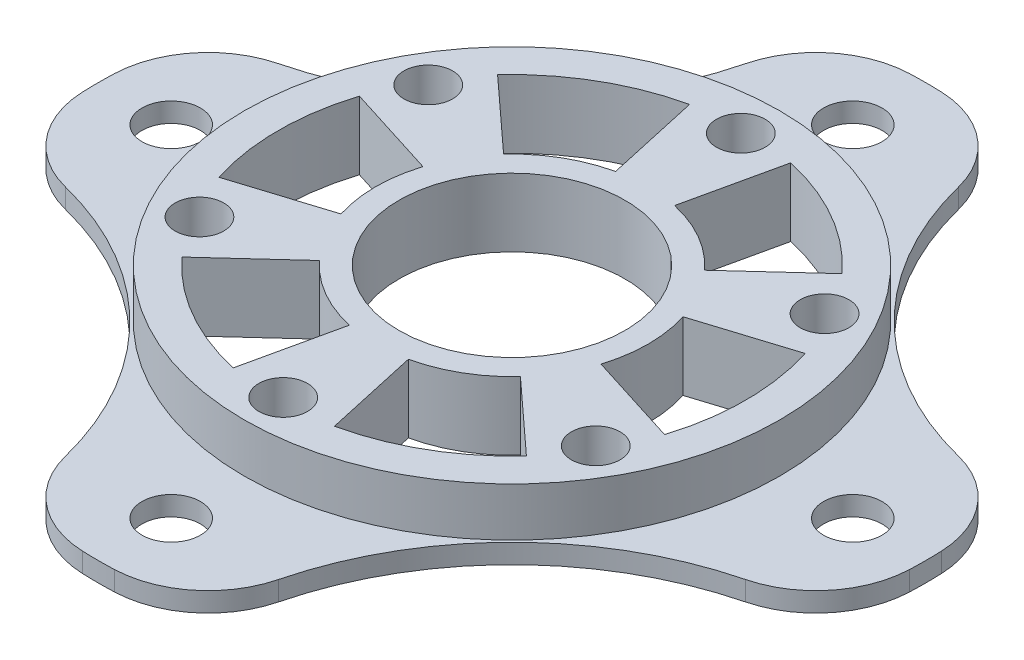
from build123d import *

# Parameters (mm, degrees)
SKETCH1_R           = 27.5
BOSS_EXTRUDE1_DEPTH = 5
SKETCH2_R           = 42.5
BOSS_EXTRUDE2_DEPTH = 2
SKETCH3_R           = 3
CUT_EXTRUDE1_DEPTH  = 2
SKETCH4_R           = 11.6
SKETCH4_R_2         = 2.5
CUT_EXTRUDE2_DEPTH  = 8
CUT_EXTRUDE3_DEPTH  = 8
FILLET1_R           = 10


with BuildPart() as part:
    # Sketch1 → Boss-Extrude1 (new body)
    with BuildSketch(Plane(origin=(0, 0, 0), x_dir=(1, 0, 0), z_dir=(0, 1, 0))):
        Circle(SKETCH1_R)
    extrude(amount=-BOSS_EXTRUDE1_DEPTH)

    # Sketch2 → Boss-Extrude2 (add)
    with BuildSketch(Plane.XZ.offset(5)):
        Circle(SKETCH2_R)
    extrude(amount=BOSS_EXTRUDE2_DEPTH)

    # Sketch3 → Cut-Extrude1 (cut)
    with BuildSketch(Plane(origin=(0, -5, 0), x_dir=(1, 0, 0), z_dir=(0, 1, 0))):
        with BuildLine():
            ThreePointArc((-41.306779105, 10), (-19.624107624, 19.624107624), (-10, 41.306779105))
            ThreePointArc((-10, 41.306779105), (-30.0520382, 30.0520382), (-41.306779105, 10))
        make_face()
        with Locations((0, 35)):
            Circle(SKETCH3_R)
        with BuildLine():
            ThreePointArc((41.306779105, 10), (30.0520382, 30.0520382), (10, 41.306779105))
            ThreePointArc((10, 41.306779105), (19.624107624, 19.624107624), (41.306779105, 10))
        make_face()
        with Locations((35, 0)):
            Circle(SKETCH3_R)
        with Locations((0, -35)):
            Circle(SKETCH3_R)
        with BuildLine():
            ThreePointArc((41.306779105, -10), (19.624107624, -19.624107624), (10, -41.306779105))
            ThreePointArc((10, -41.306779105), (30.0520382, -30.0520382), (41.306779105, -10))
        make_face()
        with BuildLine():
            ThreePointArc((-10, -41.306779105), (-19.624107624, -19.624107624), (-41.306779105, -10))
            ThreePointArc((-41.306779105, -10), (-30.0520382, -30.0520382), (-10, -41.306779105))
        make_face()
        with Locations((-35, 0)):
            Circle(SKETCH3_R)
    extrude(amount=-CUT_EXTRUDE1_DEPTH, mode=Mode.SUBTRACT)

    # Sketch4 → Cut-Extrude2 (cut, through all)
    with BuildSketch(Plane(origin=(0, 0, 0), x_dir=(1, 0, 0), z_dir=(0, 1, 0))):
        Circle(SKETCH4_R)
        with Locations((0, 23.5)):
            Circle(SKETCH4_R_2)
        with Locations((20.351596989, 11.75)):
            Circle(SKETCH4_R_2)
        with Locations((20.351596989, -11.75)):
            Circle(SKETCH4_R_2)
        with Locations((0, -23.5)):
            Circle(SKETCH4_R_2)
        with Locations((-20.351596989, -11.75)):
            Circle(SKETCH4_R_2)
        with Locations((-20.351596989, 11.75)):
            Circle(SKETCH4_R_2)
    extrude(amount=-CUT_EXTRUDE2_DEPTH, mode=Mode.SUBTRACT)

    # Sketch5 → Cut-Extrude3 (cut, through all)
    with BuildSketch(Plane(origin=(0, 0, 0), x_dir=(1, 0, 0), z_dir=(0, 1, 0))):
        with BuildLine():
            Line((-17.694656083, 16.214164983), (-10.321882715, 9.458262907))
            ThreePointArc((-10.321882715, 9.458262907), (-7, 12.124355653), (-3.030154595, 13.6681441))
            Line((-3.030154595, 13.6681441), (-5.194550735, 23.431104171))
            ThreePointArc((-5.194550735, 23.431104171), (-12, 20.784609691), (-17.694656083, 16.214164983))
        make_face()
        with BuildLine():
            Line((17.694656083, 16.214164983), (10.321882715, 9.458262907))
            ThreePointArc((10.321882715, 9.458262907), (7, 12.124355653), (3.030154595, 13.6681441))
            Line((3.030154595, 13.6681441), (5.194550735, 23.431104171))
            ThreePointArc((5.194550735, 23.431104171), (12, 20.784609691), (17.694656083, 16.214164983))
        make_face()
        with BuildLine():
            Line((22.889206818, -7.216939188), (13.35203731, -4.209881193))
            ThreePointArc((13.35203731, -4.209881193), (14, 0), (13.35203731, 4.209881193))
            Line((13.35203731, 4.209881193), (22.889206818, 7.216939188))
            ThreePointArc((22.889206818, 7.216939188), (24, 0), (22.889206818, -7.216939188))
        make_face()
        with BuildLine():
            Line((5.194550735, -23.431104171), (3.030154595, -13.6681441))
            ThreePointArc((3.030154595, -13.6681441), (7, -12.124355653), (10.321882715, -9.458262907))
            Line((10.321882715, -9.458262907), (17.694656083, -16.214164983))
            ThreePointArc((17.694656083, -16.214164983), (12, -20.784609691), (5.194550735, -23.431104171))
        make_face()
        with BuildLine():
            Line((-17.694656083, -16.214164983), (-10.321882715, -9.458262907))
            ThreePointArc((-10.321882715, -9.458262907), (-7, -12.124355653), (-3.030154595, -13.6681441))
            Line((-3.030154595, -13.6681441), (-5.194550735, -23.431104171))
            ThreePointArc((-5.194550735, -23.431104171), (-12, -20.784609691), (-17.694656083, -16.214164983))
        make_face()
        with BuildLine():
            Line((-22.889206818, 7.216939188), (-13.35203731, 4.209881193))
            ThreePointArc((-13.35203731, 4.209881193), (-14, 0), (-13.35203731, -4.209881193))
            Line((-13.35203731, -4.209881193), (-22.889206818, -7.216939188))
            ThreePointArc((-22.889206818, -7.216939188), (-24, 0), (-22.889206818, 7.216939188))
        make_face()
    extrude(amount=-CUT_EXTRUDE3_DEPTH, mode=Mode.SUBTRACT)

    # Fillet1
    fillet1_edges = [part.edges().sort_by_distance(p)[0] for p in [
        (41.306779105, -6, -10),
        (10, -6, -41.306779105),
        (10, -6, 41.306779105),
        (41.306779105, -6, 10),
        (-41.306779105, -6, 10),
        (-10, -6, 41.306779105),
        (-10, -6, -41.306779105),
        (-41.306779105, -6, -10),
    ]]
    fillet(fillet1_edges, radius=FILLET1_R)


solid = part.part
